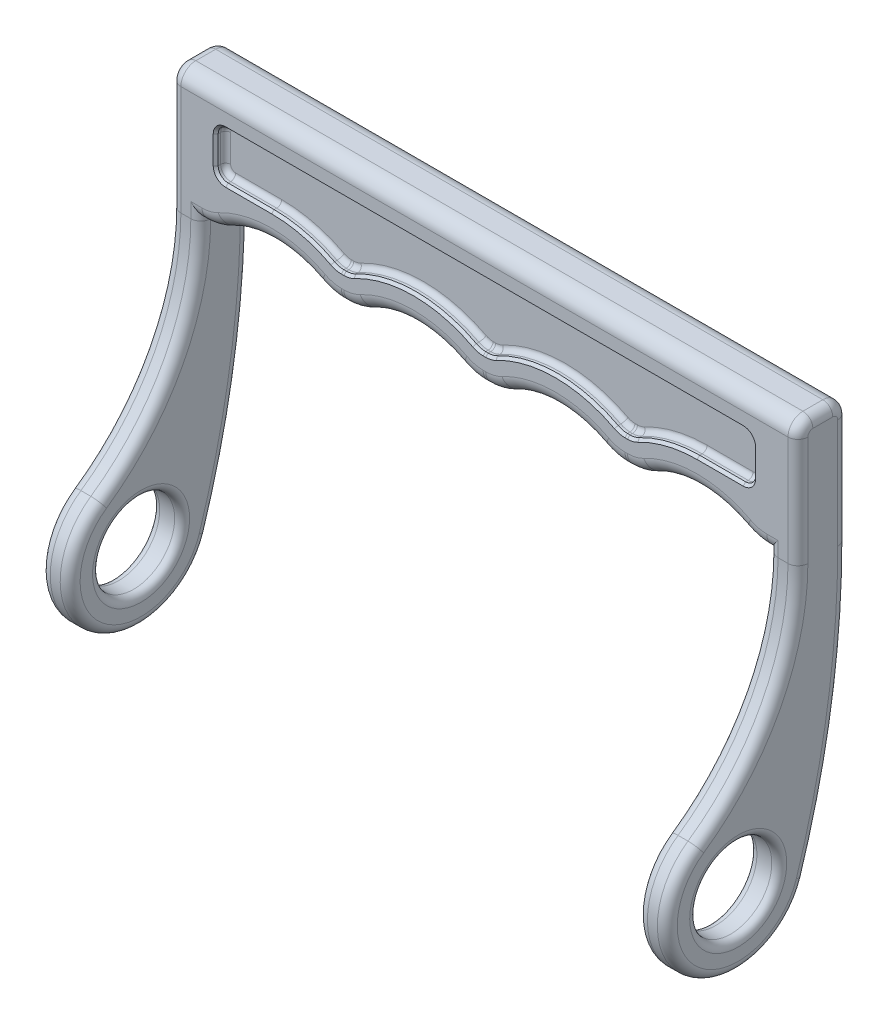
from build123d import *

# Parameters (mm, degrees)
SKETCH3_W           = 114
SKETCH3_H           = 25
BOSS_EXTRUDE1_DEPTH = 5
CUT_EXTRUDE1_DEPTH  = 11
CUT_EXTRUDE2_DEPTH  = 2
SKETCH6_R           = 8.25
BOSS_EXTRUDE2_DEPTH = 6
FILLET1_R           = 10
FILLET2_R           = 3
FILLET3_R           = 2
FILLET4_R           = 1.5
FILLET5_R           = 1
FILLET6_R           = 1
CHAMFER1_SIZE       = 0.5


with BuildPart() as part:
    # Sketch3 → Boss-Extrude1 (new body, symmetric)
    with BuildSketch(Plane.XY):
        Rectangle(SKETCH3_W, SKETCH3_H)
    extrude(amount=BOSS_EXTRUDE1_DEPTH, both=True)

    # Sketch4 → Cut-Extrude1 (cut, through all)
    with BuildSketch(Plane.XY.offset(5)):
        with BuildLine():
            Line((31.5, -12.5), (54, -12.5))
            ThreePointArc((54, -12.5), (42.75, -9.035945694), (31.5, -12.5))
        make_face()
        with BuildLine():
            Line((3, -12.5), (25.5, -12.5))
            ThreePointArc((25.5, -12.5), (14.25, -9.035945694), (3, -12.5))
        make_face()
        with BuildLine():
            Line((-25.5, -12.5), (-3, -12.5))
            ThreePointArc((-3, -12.5), (-14.25, -9.035945694), (-25.5, -12.5))
        make_face()
        with BuildLine():
            Line((-54, -12.5), (-31.5, -12.5))
            ThreePointArc((-31.5, -12.5), (-42.75, -9.035945694), (-54, -12.5))
        make_face()
    extrude(amount=-CUT_EXTRUDE1_DEPTH, mode=Mode.SUBTRACT)

    # Sketch5 → Cut-Extrude2 (cut)
    with BuildSketch(Plane.XY.offset(5)):
        with BuildLine():
            Line((-54, -1.035945694), (-54, 4.5))
            ThreePointArc((-54, 4.5), (-53.414213562, 5.914213562), (-52, 6.5))
            Line((-52, 6.5), (52, 6.5))
            ThreePointArc((52, 6.5), (53.414213562, 5.914213562), (54, 4.5))
            Line((54, 4.5), (54, -1.035945694))
            ThreePointArc((54, -1.035945694), (53.414213562, -2.450159257), (52, -3.035945694))
            Line((52, -3.035945694), (42.75, -3.035945694))
            ThreePointArc((42.75, -3.035945694), (36.502732983, -3.797648311), (30.621509015, -6.038126093))
            ThreePointArc((30.621509015, -6.038126093), (29.716705328, -6.382814982), (28.755587325, -6.5))
            Line((28.755587325, -6.5), (28.244412675, -6.5))
            ThreePointArc((28.244412675, -6.5), (27.283294672, -6.382814982), (26.378490985, -6.038126093))
            ThreePointArc((26.378490985, -6.038126093), (14.25, -3.035945694), (2.121509015, -6.038126093))
            ThreePointArc((2.121509015, -6.038126093), (1.216705328, -6.382814982), (0.255587325, -6.5))
            Line((0.255587325, -6.5), (-0.255587325, -6.5))
            ThreePointArc((-0.255587325, -6.5), (-1.216705328, -6.382814982), (-2.121509015, -6.038126093))
            ThreePointArc((-2.121509015, -6.038126093), (-14.25, -3.035945694), (-26.378490985, -6.038126093))
            ThreePointArc((-26.378490985, -6.038126093), (-27.283294672, -6.382814982), (-28.244412675, -6.5))
            Line((-28.244412675, -6.5), (-28.755587325, -6.5))
            ThreePointArc((-28.755587325, -6.5), (-29.716705328, -6.382814982), (-30.621509015, -6.038126093))
            ThreePointArc((-30.621509015, -6.038126093), (-36.502732983, -3.797648311), (-42.75, -3.035945694))
            Line((-42.75, -3.035945694), (-52, -3.035945694))
            ThreePointArc((-52, -3.035945694), (-53.414213562, -2.450159257), (-54, -1.035945694))
        make_face()
    cut_extrude2 = extrude(amount=-CUT_EXTRUDE2_DEPTH, mode=Mode.SUBTRACT)

    # Mirror1: Cut-Extrude2 across plane
    add(cut_extrude2.mirror(Plane.XY), mode=Mode.SUBTRACT)

    # Sketch6 → Boss-Extrude2 (add)
    with BuildSketch(Plane(origin=(57, 0, 0), x_dir=(0, 0, -1), z_dir=(1, 0, 0))):
        with BuildLine():
            Line((5, -12.5), (5, 12.5))
            Line((5, 12.5), (-5, 12.5))
            Line((-5, 12.5), (-5, -12.5))
            ThreePointArc((-5, -12.5), (-10.328315363, -34.112009435), (-25.091989221, -50.770455659))
            ThreePointArc((-25.091989221, -50.770455659), (-25.478264988, -73.953450257), (-3.418648226, -66.813859525))
            ThreePointArc((-3.418648226, -66.813859525), (2.882846426, -39.981216196), (5, -12.5))
        make_face()
        with Locations((-17, -62.5)):
            Circle(SKETCH6_R, mode=Mode.SUBTRACT)
    boss_extrude2 = extrude(amount=BOSS_EXTRUDE2_DEPTH)

    # Mirror2: Boss-Extrude2 across plane
    add(boss_extrude2.mirror(Plane(origin=(0, 0, 0), x_dir=(0, 0, 1), z_dir=(1, 0, 0))))

    # Fillet1
    fillet1_edges = [part.edges().sort_by_distance(p)[0] for p in [
        (31.5, -12.5, 0),
        (54, -12.5, 0),
        (3, -12.5, 0),
        (25.5, -12.5, 0),
        (-25.5, -12.5, 0),
        (-3, -12.5, 0),
        (-54, -12.5, 0),
        (-31.5, -12.5, 0),
    ]]
    fillet(fillet1_edges, radius=FILLET1_R)

    # Fillet2
    fillet2_edges = [part.edges().sort_by_distance(p)[0] for p in [
        (-56.872206337, -12.5, 5),
        (42.75, -9.035945694, 5),
        (42.75, -9.035945694, -5),
        (28.5, -12.5, 5),
        (56.872206337, -12.5, 5),
        (-42.75, -9.035945694, 5),
        (-28.5, -12.5, 5),
        (-14.25, -9.035945694, 5),
        (0, -12.5, 5),
        (14.25, -9.035945694, 5),
        (-54.341617668, -12.207037455, 5),
        (-31.158382332, -12.207037455, 5),
        (-25.841617668, -12.207037455, 5),
        (-2.658382332, -12.207037455, 5),
        (2.658382332, -12.207037455, 5),
        (25.841617668, -12.207037455, 5),
        (31.158382332, -12.207037455, 5),
        (54.341617668, -12.207037455, 5),
        (56.872206337, -12.5, -5),
        (28.5, -12.5, -5),
        (14.25, -9.035945694, -5),
        (0, -12.5, -5),
        (-14.25, -9.035945694, -5),
        (-28.5, -12.5, -5),
        (-42.75, -9.035945694, -5),
        (-54.341617668, -12.207037455, -5),
        (-31.158382332, -12.207037455, -5),
        (-25.841617668, -12.207037455, -5),
        (-2.658382332, -12.207037455, -5),
        (2.658382332, -12.207037455, -5),
        (25.841617668, -12.207037455, -5),
        (31.158382332, -12.207037455, -5),
        (54.341617668, -12.207037455, -5),
        (-56.872206337, -12.5, -5),
        (0, 12.5, -5),
        (0, 12.5, 5),
    ]]
    fillet(fillet2_edges, radius=FILLET2_R)

    # Fillet3
    fillet3_edges = [part.edges().sort_by_distance(p)[0] for p in [
        (63, -39.981216196, -2.882846426),
        (63, -1.5, -5),
        (63, -34.112009435, 10.328315363),
        (63, -73.953450257, 25.478264988),
        (57, -39.981216196, -2.882846426),
        (57, -34.112009435, 10.328315363),
        (57, -73.953450257, 25.478264988),
        (-57, -34.112009435, 10.328315363),
        (-57, -73.953450257, 25.478264988),
        (-57, -39.981216196, -2.882846426),
        (-63, -39.981216196, -2.882846426),
        (-63, -73.953450257, 25.478264988),
        (-63, -34.112009435, 10.328315363),
        (-63, -1.5, -5),
        (57, -11, -5),
        (-57, -11, -5),
        (63, -1.5, 5),
        (-63, -1.5, 5),
        (-57, -11, 5),
        (57, -11, 5),
        (-63, 12.5, 0),
        (63, 12.5, 0),
        (-63, 11.621320344, 4.121320344),
        (-63, 11.621320344, -4.121320344),
        (63, 11.621320344, 4.121320344),
        (63, 11.621320344, -4.121320344),
    ]]
    fillet(fillet3_edges, radius=FILLET3_R)

    # Fillet4
    fillet4_edges = [part.edges().sort_by_distance(p)[0] for p in [
        (57, -62.5, 25.25),
        (63, -62.5, 25.25),
        (-63, -62.5, 25.25),
        (-57, -62.5, 25.25),
    ]]
    fillet(fillet4_edges, radius=FILLET4_R)

    # Fillet5
    fillet5_edges = [part.edges().sort_by_distance(p)[0] for p in [
        (53.414213562, -2.450159257, 3),
        (47.375, -3.035945694, 3),
        (36.502732983, -3.797648311, 3),
        (29.716705328, -6.382814982, 3),
        (28.5, -6.5, 3),
        (27.283294672, -6.382814982, 3),
        (14.25, -3.035945694, 3),
        (1.216705328, -6.382814982, 3),
        (0, -6.5, 3),
        (-1.216705328, -6.382814982, 3),
        (-14.25, -3.035945694, 3),
        (-27.283294672, -6.382814982, 3),
        (-28.5, -6.5, 3),
        (-29.716705328, -6.382814982, 3),
        (-36.502732983, -3.797648311, 3),
        (-47.375, -3.035945694, 3),
        (-53.414213562, -2.450159257, 3),
        (-54, 1.732027153, 3),
        (-53.414213562, 5.914213562, 3),
        (0, 6.5, 3),
        (53.414213562, 5.914213562, 3),
        (54, 1.732027153, 3),
    ]]
    fillet(fillet5_edges, radius=FILLET5_R)

    # Fillet6
    fillet6_edges = [part.edges().sort_by_distance(p)[0] for p in [
        (53.414213562, -2.450159257, -3),
        (54, 1.732027153, -3),
        (53.414213562, 5.914213562, -3),
        (0, 6.5, -3),
        (-53.414213562, 5.914213562, -3),
        (-54, 1.732027153, -3),
        (-53.414213562, -2.450159257, -3),
        (-47.375, -3.035945694, -3),
        (-36.502732983, -3.797648311, -3),
        (-29.716705328, -6.382814982, -3),
        (-28.5, -6.5, -3),
        (-27.283294672, -6.382814982, -3),
        (-14.25, -3.035945694, -3),
        (-1.216705328, -6.382814982, -3),
        (0, -6.5, -3),
        (1.216705328, -6.382814982, -3),
        (14.25, -3.035945694, -3),
        (27.283294672, -6.382814982, -3),
        (28.5, -6.5, -3),
        (29.716705328, -6.382814982, -3),
        (36.502732983, -3.797648311, -3),
        (47.375, -3.035945694, -3),
    ]]
    fillet(fillet6_edges, radius=FILLET6_R)

    # Chamfer1
    chamfer1_edges = [part.edges().sort_by_distance(p)[0] for p in [
        (53.414213562, -2.450159257, -5),
        (54, 1.732027153, -5),
        (53.414213562, 5.914213562, -5),
        (0, 6.5, -5),
        (-53.414213562, 5.914213562, -5),
        (-54, 1.732027153, -5),
        (-53.414213562, -2.450159257, -5),
        (-47.375, -3.035945694, -5),
        (-36.502732983, -3.797648311, -5),
        (-29.716705328, -6.382814982, -5),
        (-28.5, -6.5, -5),
        (-27.283294672, -6.382814982, -5),
        (-14.25, -3.035945694, -5),
        (-1.216705328, -6.382814982, -5),
        (0, -6.5, -5),
        (1.216705328, -6.382814982, -5),
        (14.25, -3.035945694, -5),
        (27.283294672, -6.382814982, -5),
        (28.5, -6.5, -5),
        (29.716705328, -6.382814982, -5),
        (36.502732983, -3.797648311, -5),
        (47.375, -3.035945694, -5),
        (53.414213562, -2.450159257, 5),
        (54, 1.732027153, 5),
        (53.414213562, 5.914213562, 5),
        (0, 6.5, 5),
        (-53.414213562, 5.914213562, 5),
        (-54, 1.732027153, 5),
        (-53.414213562, -2.450159257, 5),
        (-47.375, -3.035945694, 5),
        (-36.502732983, -3.797648311, 5),
        (-29.716705328, -6.382814982, 5),
        (-28.5, -6.5, 5),
        (-27.283294672, -6.382814982, 5),
        (-14.25, -3.035945694, 5),
        (-1.216705328, -6.382814982, 5),
        (0, -6.5, 5),
        (1.216705328, -6.382814982, 5),
        (14.25, -3.035945694, 5),
        (27.283294672, -6.382814982, 5),
        (28.5, -6.5, 5),
        (29.716705328, -6.382814982, 5),
        (36.502732983, -3.797648311, 5),
        (47.375, -3.035945694, 5),
    ]]
    chamfer(chamfer1_edges, length=CHAMFER1_SIZE)


solid = part.part
